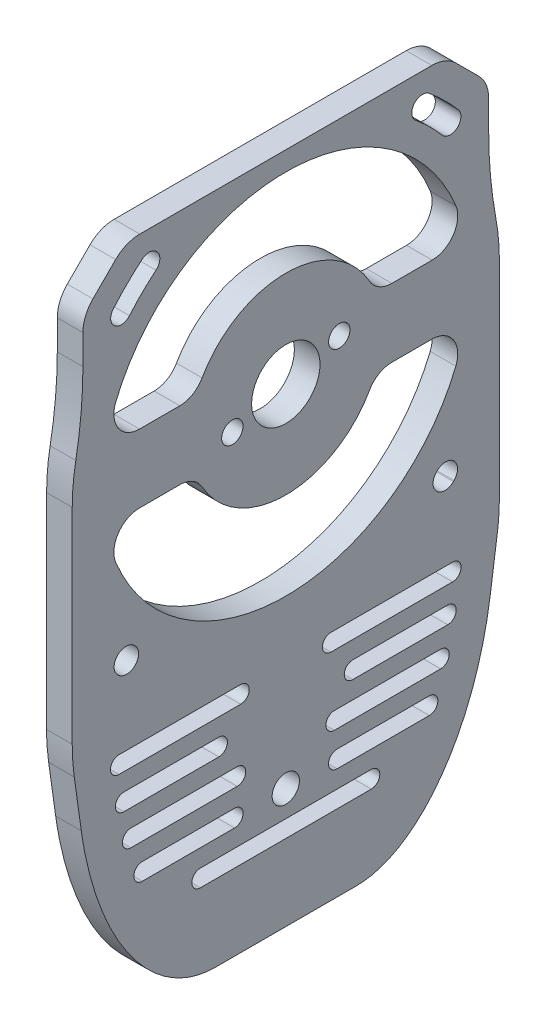
from build123d import *

# Parameters (mm, degrees)
SKETCH2_R           = 21.5
BOSS_EXTRUDE1_DEPTH = 3
CUT_EXTRUDE1_DEPTH  = 4.0000001
SKETCH4_R           = 1.6
CUT_EXTRUDE2_DEPTH  = 4.0000001
CUT_EXTRUDE3_DEPTH  = 4.0000001
BOSS_EXTRUDE3_DEPTH = 3
FILLET1_R           = 3
SKETCH7_R           = 4
CUT_EXTRUDE4_DEPTH  = 4.0000001


with BuildPart() as part:
    # Sketch2 → Boss-Extrude1 (new body)
    with BuildSketch(Plane.ZY.offset(80.1)):
        with BuildLine():
            ThreePointArc((-17.093145751, 29.75), (-18.62387948, 29.44551813), (-19.921572875, 28.578427125))
            Line((-19.921572875, 28.578427125), (-22.578427125, 25.921572875))
            ThreePointArc((-22.578427125, 25.921572875), (-23.44551813, 24.62387948), (-23.75, 23.093145751))
            Line((-23.75, 23.093145751), (-23.75, 19.635890143))
            ThreePointArc((-23.75, 19.635890143), (-23.958769179, 15.071535497), (-24.583333333, 10.545296714))
            ThreePointArc((-24.583333333, 10.545296714), (-24.89561541, 8.282177323), (-25, 6))
            Line((-25, 6), (-25, -18.013516259))
            add(Edge.make_bspline(
                [(-25, -18.013516259), (-25, -19.75), (-24.760179539, -21.458720786)],
                knots=[4.71238898, 4.71238898, 4.71238898, 4.891446603, 4.891446603, 4.891446603], degree=2, weights=[1, 0.995994972, 1]))
            Line((-24.760179539, -21.458720786), (-23.936908844, -27.324524486))
            add(Edge.make_bspline(
                [(-23.936908844, -27.324524486), (-20.894736842, -49), (-8.26270655, -49)],
                knots=[1.708421538, 1.708421538, 1.708421538, 3.107039678, 3.107039678, 3.107039678], degree=2, weights=[1, 0.765287114, 1]))
            Line((-8.26270655, -49), (8.26270655, -49))
            add(Edge.make_bspline(
                [(8.26270655, -49), (20.894736842, -49), (23.936908844, -27.324524486)],
                knots=[0.034552975, 0.034552975, 0.034552975, 1.433171116, 1.433171116, 1.433171116], degree=2, weights=[1, 0.765287114, 1]))
            Line((23.936908844, -27.324524486), (24.760179539, -21.458720786))
            add(Edge.make_bspline(
                [(24.760179539, -21.458720786), (25, -19.75), (25, -18.013516259)],
                knots=[1.391738704, 1.391738704, 1.391738704, 1.570796327, 1.570796327, 1.570796327], degree=2, weights=[1, 0.995994972, 1]))
            Line((25, -18.013516259), (25, 6))
            ThreePointArc((25, 6), (24.89561541, 8.282177323), (24.583333333, 10.545296714))
            ThreePointArc((24.583333333, 10.545296714), (23.958769179, 15.071535497), (23.75, 19.635890143))
            Line((23.75, 19.635890143), (23.75, 23.093145751))
            ThreePointArc((23.75, 23.093145751), (23.44551813, 24.62387948), (22.578427125, 25.921572875))
            Line((22.578427125, 25.921572875), (19.921572875, 28.578427125))
            ThreePointArc((19.921572875, 28.578427125), (18.62387948, 29.44551813), (17.093145751, 29.75))
            Line((17.093145751, 29.75), (-17.093145751, 29.75))
        make_face()
        with Locations((0, 6)):
            Circle(SKETCH2_R, mode=Mode.SUBTRACT)
    extrude(amount=BOSS_EXTRUDE1_DEPTH)

    # Sketch3 → Cut-Extrude1 (cut, through all)
    with BuildSketch(Plane.ZY.offset(83.1)):
        with BuildLine():
            ThreePointArc((-15.196569313, 25.146541488), (-15.032451192, 26.906673654), (-16.792583358, 27.070791775))
            ThreePointArc((-16.792583358, 27.070791775), (-18.571456346, 25.459260737), (-20.203027197, 23.698750028))
            ThreePointArc((-20.203027197, 23.698750028), (-20.058850519, 21.936872312), (-18.296972803, 22.081048991))
            ThreePointArc((-18.296972803, 22.081048991), (-16.813726575, 23.681513271), (-15.196569313, 25.146541488))
        make_face()
        with BuildLine():
            ThreePointArc((-19.691847489, -13.623229665), (-19.657568517, -13.657568517), (-19.623229665, -13.691847489))
            ThreePointArc((-19.623229665, -13.691847489), (-17.643333693, -13.688391915), (-17.646789267, -11.708495943))
            ThreePointArc((-17.646789267, -11.708495943), (-17.67766953, -11.67766953), (-17.708495943, -11.646789267))
            ThreePointArc((-17.708495943, -11.646789267), (-19.688391915, -11.643333693), (-19.691847489, -13.623229665))
        make_face()
        with BuildLine():
            ThreePointArc((17.646789267, -11.708495943), (17.67766953, -11.67766953), (17.708495943, -11.646789267))
            ThreePointArc((17.708495943, -11.646789267), (19.688391915, -11.643333693), (19.691847489, -13.623229665))
            ThreePointArc((19.691847489, -13.623229665), (19.657568517, -13.657568517), (19.623229665, -13.691847489))
            ThreePointArc((19.623229665, -13.691847489), (17.643333693, -13.688391915), (17.646789267, -11.708495943))
        make_face()
        with BuildLine():
            ThreePointArc((18.296972803, 22.081048991), (16.813726575, 23.681513271), (15.196569313, 25.146541488))
            ThreePointArc((15.196569313, 25.146541488), (15.032451192, 26.906673654), (16.792583358, 27.070791775))
            ThreePointArc((16.792583358, 27.070791775), (18.571456346, 25.459260737), (20.203027197, 23.698750028))
            ThreePointArc((20.203027197, 23.698750028), (20.058850519, 21.936872312), (18.296972803, 22.081048991))
        make_face()
    extrude(amount=-CUT_EXTRUDE1_DEPTH, mode=Mode.SUBTRACT)

    # Sketch4 → Cut-Extrude2 (cut, through all)
    with BuildSketch(Plane(origin=(-80.1, 0, 0), x_dir=(0, 0, -1), z_dir=(1, 0, 0))):
        with Locations((0, -35)):
            Circle(SKETCH4_R)
    extrude(amount=-CUT_EXTRUDE2_DEPTH, mode=Mode.SUBTRACT)

    # Sketch5 → Cut-Extrude3 (cut, through all)
    with BuildSketch(Plane(origin=(-80.1, 0, 0), x_dir=(0, 0, -1), z_dir=(1, 0, 0))):
        with BuildLine():
            Line((-19.521169673, -21.8125), (-5.284461571, -21.8125))
            ThreePointArc((-5.284461571, -21.8125), (-4.284461571, -22.8125), (-5.284461571, -23.8125))
            Line((-5.284461571, -23.8125), (-19.521169673, -23.8125))
            ThreePointArc((-19.521169673, -23.8125), (-20.521169673, -22.8125), (-19.521169673, -21.8125))
        make_face()
        with BuildLine():
            Line((-18.950227736, -25.875), (-7.838149252, -25.875))
            ThreePointArc((-7.838149252, -25.875), (-6.838149252, -26.875), (-7.838149252, -27.875))
            Line((-7.838149252, -27.875), (-18.950227736, -27.875))
            ThreePointArc((-18.950227736, -27.875), (-19.950227736, -26.875), (-18.950227736, -25.875))
        make_face()
        with BuildLine():
            Line((-16.793141988, -34), (-6, -34))
            ThreePointArc((-6, -34), (-5, -35), (-6, -36))
            Line((-6, -36), (-16.793141988, -36))
            ThreePointArc((-16.793141988, -36), (-17.793141988, -35), (-16.793141988, -34))
        make_face()
        with BuildLine():
            Line((-10, -38.0625), (10, -38.0625))
            ThreePointArc((10, -38.0625), (11, -39.0625), (10, -40.0625))
            Line((10, -40.0625), (-10, -40.0625))
            ThreePointArc((-10, -40.0625), (-11, -39.0625), (-10, -38.0625))
        make_face()
        with BuildLine():
            Line((-18.129953736, -29.9375), (-5.690263266, -29.9375))
            ThreePointArc((-5.690263266, -29.9375), (-4.690263266, -30.9375), (-5.690263266, -31.9375))
            Line((-5.690263266, -31.9375), (-18.129953736, -31.9375))
            ThreePointArc((-18.129953736, -31.9375), (-19.129953736, -30.9375), (-18.129953736, -29.9375))
        make_face()
        with BuildLine():
            Line((19.521169673, -21.8125), (5.284461571, -21.8125))
            ThreePointArc((5.284461571, -21.8125), (4.284461571, -22.8125), (5.284461571, -23.8125))
            Line((5.284461571, -23.8125), (19.521169673, -23.8125))
            ThreePointArc((19.521169673, -23.8125), (20.521169673, -22.8125), (19.521169673, -21.8125))
        make_face()
        with BuildLine():
            Line((18.950227736, -25.875), (7.838149252, -25.875))
            ThreePointArc((7.838149252, -25.875), (6.838149252, -26.875), (7.838149252, -27.875))
            Line((7.838149252, -27.875), (18.950227736, -27.875))
            ThreePointArc((18.950227736, -27.875), (19.950227736, -26.875), (18.950227736, -25.875))
        make_face()
        with BuildLine():
            Line((16.793141988, -34), (6, -34))
            ThreePointArc((6, -34), (5, -35), (6, -36))
            Line((6, -36), (16.793141988, -36))
            ThreePointArc((16.793141988, -36), (17.793141988, -35), (16.793141988, -34))
        make_face()
        with BuildLine():
            Line((18.129953736, -29.9375), (5.690263266, -29.9375))
            ThreePointArc((5.690263266, -29.9375), (4.690263266, -30.9375), (5.690263266, -31.9375))
            Line((5.690263266, -31.9375), (18.129953736, -31.9375))
            ThreePointArc((18.129953736, -31.9375), (19.129953736, -30.9375), (18.129953736, -29.9375))
        make_face()
    extrude(amount=-CUT_EXTRUDE3_DEPTH, mode=Mode.SUBTRACT)

    # Sketch6 → Boss-Extrude3 (add)
    with BuildSketch(Plane.ZY.offset(83.1)):
        with BuildLine():
            Line((-21.5, 2), (-10.514870422, 2))
            ThreePointArc((-10.514870422, 2), (-11.25, 6), (-10.514870422, 10))
            Line((-10.514870422, 10), (-21.5, 10))
            Line((-21.5, 10), (-21.5, 2))
        make_face()
        with BuildLine():
            Line((-10.514870422, 2), (10.514870422, 2))
            ThreePointArc((10.514870422, 2), (11.064691416, 3.966504518), (11.25, 6))
            ThreePointArc((11.25, 6), (11.064691416, 8.033495482), (10.514870422, 10))
            Line((10.514870422, 10), (-10.514870422, 10))
            ThreePointArc((-10.514870422, 10), (-11.25, 6), (-10.514870422, 2))
        make_face()
        with BuildLine():
            ThreePointArc((7.061208501, 3.284351593), (5.300168435, 3.438422635), (5.454239477, 5.199462701))
            ThreePointArc((5.454239477, 5.199462701), (7.215279543, 5.045391659), (7.061208501, 3.284351593))
        make_face(mode=Mode.SUBTRACT)
        with BuildLine():
            ThreePointArc((-5.454239477, 6.800537299), (-7.215279543, 6.954608341), (-7.061208501, 8.715648407))
            ThreePointArc((-7.061208501, 8.715648407), (-5.300168435, 8.561577365), (-5.454239477, 6.800537299))
        make_face(mode=Mode.SUBTRACT)
        with BuildLine():
            Line((-10.514870422, 10), (10.514870422, 10))
            ThreePointArc((10.514870422, 10), (0, 17.25), (-10.514870422, 10))
        make_face()
        with BuildLine():
            ThreePointArc((-10.514870422, 2), (0, -5.25), (10.514870422, 2))
            Line((10.514870422, 2), (-10.514870422, 2))
        make_face()
        with BuildLine():
            Line((10.514870422, 2), (21.5, 2))
            Line((21.5, 2), (21.5, 10))
            Line((21.5, 10), (10.514870422, 10))
            ThreePointArc((10.514870422, 10), (11.064691416, 8.033495482), (11.25, 6))
            ThreePointArc((11.25, 6), (11.064691416, 3.966504518), (10.514870422, 2))
        make_face()
    extrude(amount=-BOSS_EXTRUDE3_DEPTH)

    # Fillet1
    fillet1_edges = [part.edges().sort_by_distance(p)[0] for p in [
        (-81.6, 2, -21.124630174),
        (-81.6, 10, -21.124630174),
        (-81.6, 10, 21.124630174),
        (-81.6, 2, 21.124630174),
        (-81.6, 2, 10.514870422),
        (-81.6, 10, 10.514870422),
        (-81.6, 10, -10.514870422),
        (-81.6, 2, -10.514870422),
    ]]
    fillet(fillet1_edges, radius=FILLET1_R)

    # Sketch7 → Cut-Extrude4 (cut, through all)
    with BuildSketch(Plane(origin=(-80.1, 0, 0), x_dir=(0, 0, -1), z_dir=(1, 0, 0))):
        with Locations((0, 6)):
            Circle(SKETCH7_R)
    extrude(amount=-CUT_EXTRUDE4_DEPTH, mode=Mode.SUBTRACT)


solid = part.part
